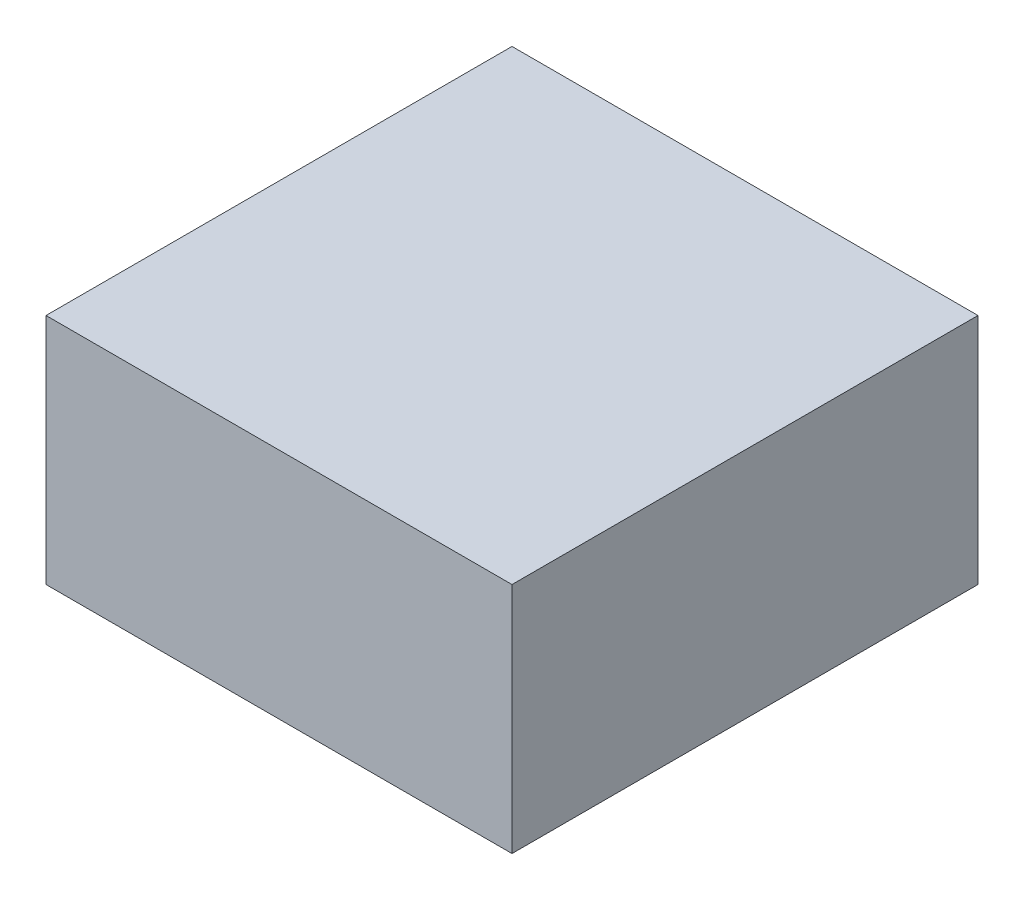
from build123d import *

# Parameters (mm, degrees)
SKETCH1_W           = 1.524
SKETCH1_H           = 1.524
BOSS_EXTRUDE1_DEPTH = 0.762


with BuildPart() as part:
    # Sketch1 → Boss-Extrude1 (new body)
    with BuildSketch(Plane(origin=(0, 0, 0), x_dir=(1, 0, 0), z_dir=(0, 1, 0))):
        with Locations((0.762, 0.762)):
            Rectangle(SKETCH1_W, SKETCH1_H)
    extrude(amount=BOSS_EXTRUDE1_DEPTH)


solid = part.part
